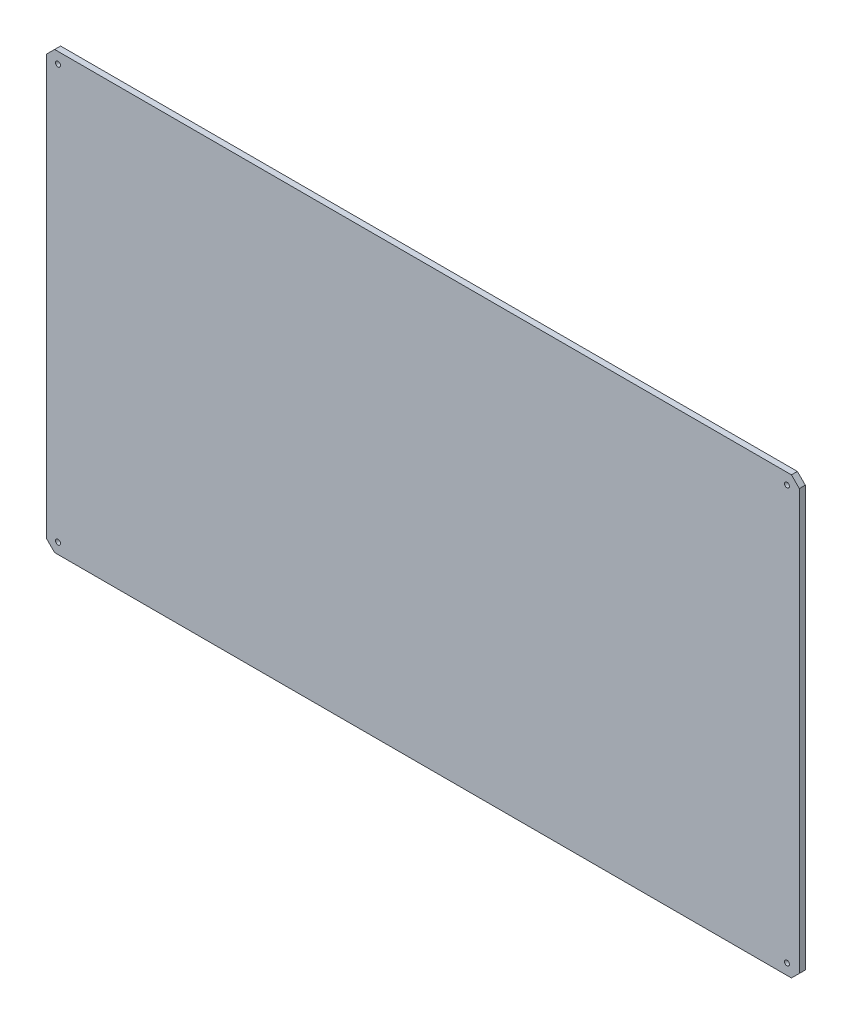
from build123d import *

# Parameters (mm, degrees)
SKETCH1_W           = 380
SKETCH1_H           = 220
BOSS_EXTRUDE1_DEPTH = 3
SKETCH2_R           = 1.25
CUT_EXTRUDE1_DEPTH  = 10
CHAMFER1_SIZE       = 4


with BuildPart() as part:
    # Sketch1 → Boss-Extrude1 (new body)
    with BuildSketch(Plane.XY):
        with Locations((10, 0)):
            Rectangle(SKETCH1_W, SKETCH1_H)
    extrude(amount=BOSS_EXTRUDE1_DEPTH)

    # Sketch2 → Cut-Extrude1 (cut)
    with BuildSketch(Plane.XY.offset(3)):
        with Locations((-174.278337167, -104.560656269)):
            Circle(SKETCH2_R)
        with Locations((-174.278337167, 104.439343731)):
            Circle(SKETCH2_R)
        with Locations((193.721662833, -104.560656269)):
            Circle(SKETCH2_R)
        with Locations((193.721662833, 104.439343731)):
            Circle(SKETCH2_R)
    extrude(amount=-CUT_EXTRUDE1_DEPTH, mode=Mode.SUBTRACT)

    # Chamfer1
    chamfer1_edges = [part.edges().sort_by_distance(p)[0] for p in [
        (200, 110, 1.5),
        (200, -110, 1.5),
        (-180, -110, 1.5),
        (-180, 110, 1.5),
    ]]
    chamfer(chamfer1_edges, length=CHAMFER1_SIZE)


solid = part.part
